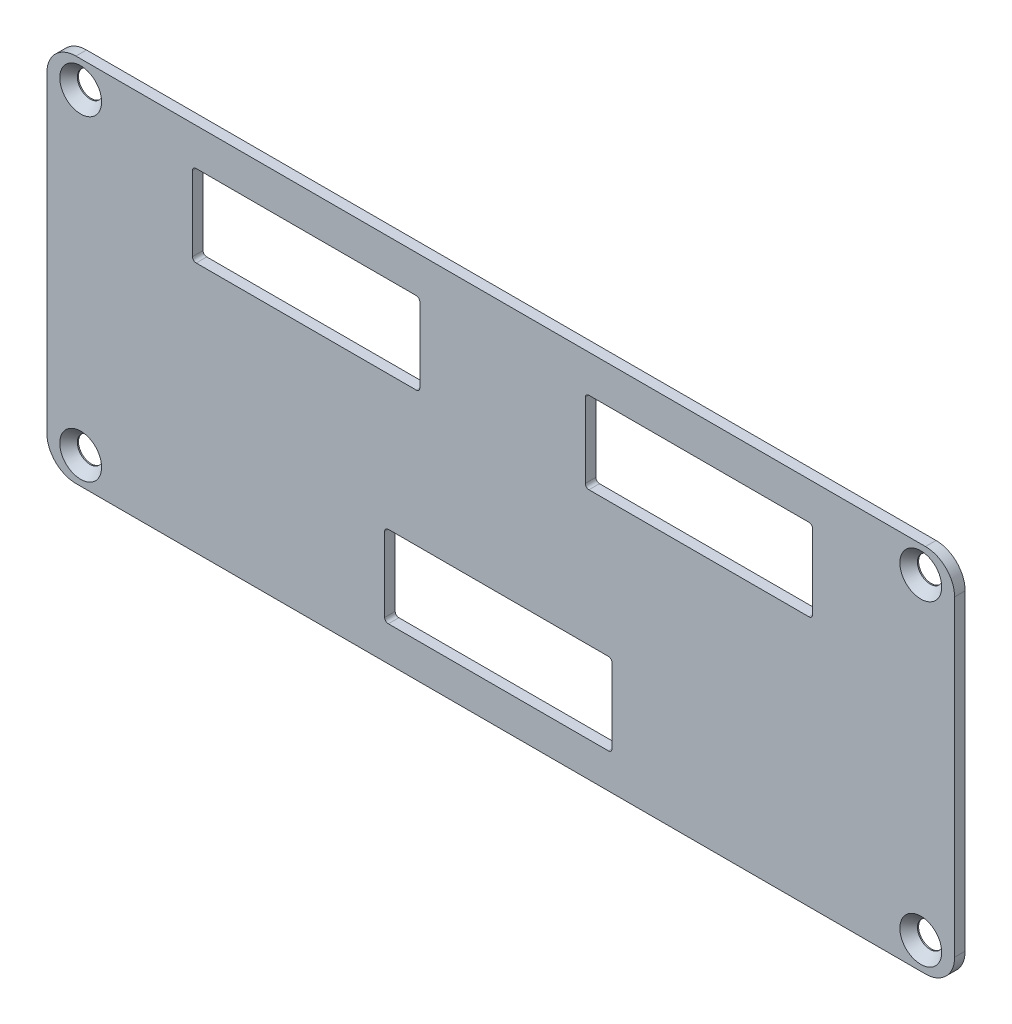
from build123d import *

# Parameters (mm, degrees)
SKETCH1_W                                      = 124.8
SKETCH1_H                                      = 50.9
BOSS_EXTRUDE1_DEPTH                            = 1.45
CSK_FOR_M3_5_FLAT_HEAD_MACHINE_SCREW1_AT_COUNT = 2
CSK_FOR_M3_5_FLAT_HEAD_MACHINE_SCREW1_AT_PITCH = 115.5
CSK_FOR_M3_5_FLAT_HEAD_MACHINE_SCREW_2_COUNT   = 2
CSK_FOR_M3_5_FLAT_HEAD_MACHINE_SCREW_2_PITCH   = 123.420014584
CSK_FOR_M3_5_FLAT_HEAD_MACHINE_SCREW_3_COUNT   = 2
CSK_FOR_M3_5_FLAT_HEAD_MACHINE_SCREW_3_PITCH   = 43.5
FILLET2_R                                      = 4
SKETCH4_W                                      = 31.25
SKETCH4_H                                      = 11.25
CUT_EXTRUDE1_DEPTH                             = 1.45
FILLET3_R                                      = 0.5


with BuildPart() as part:
    # Sketch1 → Boss-Extrude1 (new body)
    with BuildSketch(Plane.XY):
        with Locations((62.4, -25.45)):
            Rectangle(SKETCH1_W, SKETCH1_H)
    extrude(amount=BOSS_EXTRUDE1_DEPTH)

    # Sketch2 → CSK for M3.5 Flat Head Machine Screw1 (revolve, cut)
    with BuildSketch(Plane(origin=(4.65, -3.7, 1.45), x_dir=(0, -1, 0), z_dir=(1, 0, 0))):
        Polygon((0, 0), (0, 1.45), (1.75, 1.45), (1.75, 1.294164458), (2.875, 0), align=None)
    csk_for_m3_5_flat_head_machine_screw1 = revolve(axis=Axis((4.65, -3.7, 7.8), (0, 0, -1)), mode=Mode.SUBTRACT)

    # CSK for M3.5 Flat Head Machine Screw1 at: CSK for M3.5 Flat Head Machine Screw1 ×2
    with Locations(*[(i * CSK_FOR_M3_5_FLAT_HEAD_MACHINE_SCREW1_AT_PITCH, 0, 0) for i in range(1, CSK_FOR_M3_5_FLAT_HEAD_MACHINE_SCREW1_AT_COUNT)]):
        add(csk_for_m3_5_flat_head_machine_screw1, mode=Mode.SUBTRACT)

    # CSK for M3.5 Flat Head Machine Screw 2: CSK for M3.5 Flat Head Machine Screw1 ×2
    with Locations(*[Vector(0.935828766, -0.35245499, 0) * (i * CSK_FOR_M3_5_FLAT_HEAD_MACHINE_SCREW_2_PITCH) for i in range(1, CSK_FOR_M3_5_FLAT_HEAD_MACHINE_SCREW_2_COUNT)]):
        add(csk_for_m3_5_flat_head_machine_screw1, mode=Mode.SUBTRACT)

    # CSK for M3.5 Flat Head Machine Screw 3: CSK for M3.5 Flat Head Machine Screw1 ×2
    with Locations(*[(0, -i * CSK_FOR_M3_5_FLAT_HEAD_MACHINE_SCREW_3_PITCH, 0) for i in range(1, CSK_FOR_M3_5_FLAT_HEAD_MACHINE_SCREW_3_COUNT)]):
        add(csk_for_m3_5_flat_head_machine_screw1, mode=Mode.SUBTRACT)

    # Fillet2
    fillet2_edges = [part.edges().sort_by_distance(p)[0] for p in [
        (0, 0, 0.725),
        (124.8, 0, 0.725),
        (124.8, -50.9, 0.725),
        (0, -50.9, 0.725),
    ]]
    fillet(fillet2_edges, radius=FILLET2_R)

    # Sketch4 → Cut-Extrude1 (cut)
    with BuildSketch(Plane.XY):
        with Locations((35.651, -10.75)):
            Rectangle(SKETCH4_W, SKETCH4_H)
        with Locations((89.651, -10.75)):
            Rectangle(SKETCH4_W, SKETCH4_H)
        with Locations((62.069, -40.5)):
            Rectangle(SKETCH4_W, SKETCH4_H)
    extrude(amount=CUT_EXTRUDE1_DEPTH, mode=Mode.SUBTRACT)

    # Fillet3
    fillet3_edges = [part.edges().sort_by_distance(p)[0] for p in [
        (77.694, -46.125, 0.725),
        (77.694, -34.875, 0.725),
        (46.444, -34.875, 0.725),
        (46.444, -46.125, 0.725),
        (105.276, -16.375, 0.725),
        (105.276, -5.125, 0.725),
        (74.026, -5.125, 0.725),
        (74.026, -16.375, 0.725),
        (51.276, -16.375, 0.725),
        (51.276, -5.125, 0.725),
        (20.026, -5.125, 0.725),
        (20.026, -16.375, 0.725),
    ]]
    fillet(fillet3_edges, radius=FILLET3_R)


solid = part.part
